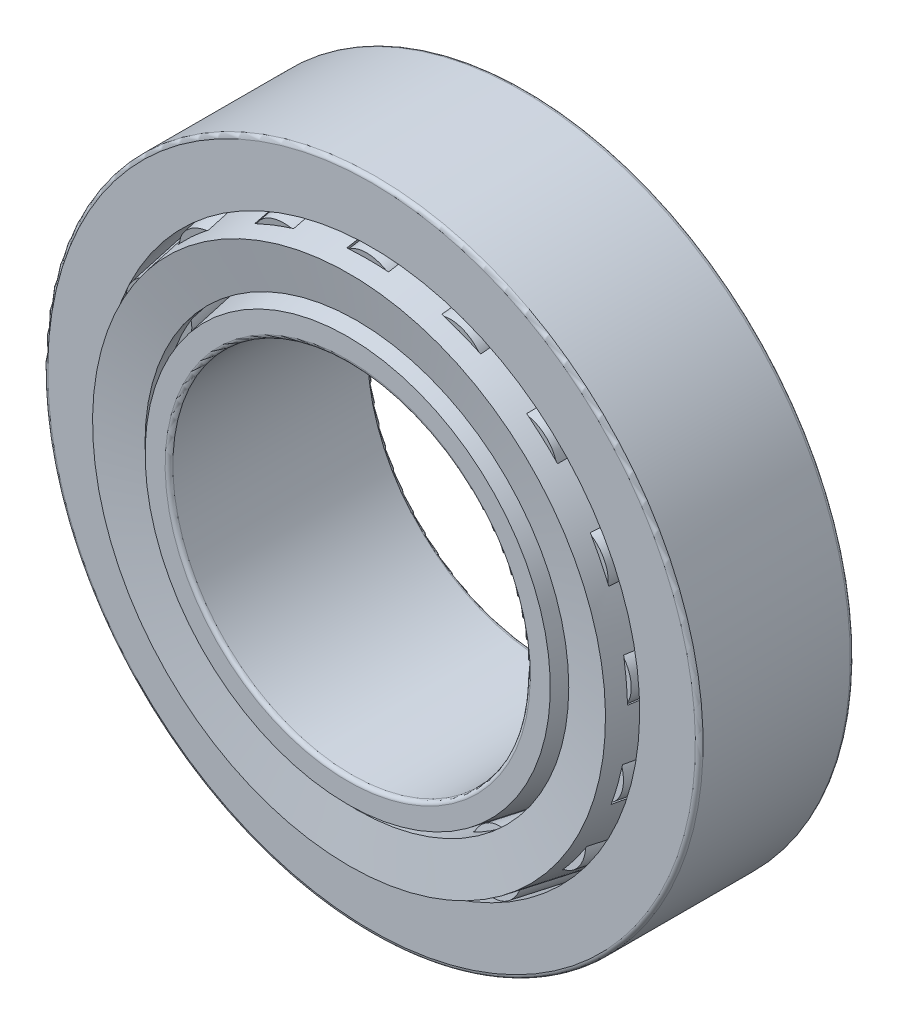
from build123d import *

# Parameters (mm, degrees)
CIRPATTERN2_COUNT = 17
CIRPATTERN1_COUNT = 17
FILLET1_R         = 0.325
FILLET2_R         = 0.325


with BuildPart() as part:
    # Sketch1 → Revolve1 (revolve)
    with BuildSketch(Plane(origin=(0, 0, 0), x_dir=(0, 0, -1), z_dir=(1, 0, 0))):
        Polygon((-6.5, 27.5), (6.5, 27.5), (6.5, 24.792250749), (-6.5, 22.5), align=None)
    revolve(axis=Axis((0, 0, 8.5), (0, 0, -1)))

    # Fillet1
    fillet1_edges = [part.edges().sort_by_distance(p)[0] for p in [
        (0, -27.5, -6.5),
        (0, -27.5, 6.5),
    ]]
    fillet(fillet1_edges, radius=FILLET1_R)


with BuildPart() as body_2:
    # Sketch5 → Revolve4 (revolve)
    with BuildSketch(Plane(origin=(0, 0, 0), x_dir=(0, 0, -1), z_dir=(1, 0, 0))):
        Polygon((8.5, 20), (-8.5, 17.002441328), (-8.5, 15), (8.5, 15), align=None)
    revolve(axis=Axis((0, 0, 8.5), (0, 0, -1)))

    # Fillet2
    fillet2_edges = [body_2.edges().sort_by_distance(p)[0] for p in [
        (0, -15, -8.5),
        (0, -15, 8.5),
    ]]
    fillet(fillet2_edges, radius=FILLET2_R)


with BuildPart() as body_3:
    # Sketch2 → Revolve2 (revolve)
    with BuildSketch(Plane(origin=(0, 0, 0), x_dir=(0, 0, -1), z_dir=(1, 0, 0))):
        Polygon((-8.390021185, 21.523625182), (-7.730148292, 17.781300044), (6.5, 20.290459127), (8.790021185, 20.694251649), (8.130148292, 24.436576787), (6.5, 24.14913766), align=None)
    revolve(axis=Axis((0, 0, 8.5), (0, 0, -1)))

    # Sketch3 → Cut-Revolve1 (revolve, cut)
    with BuildSketch(Plane(origin=(0, 0, 0), x_dir=(0, 0, -1), z_dir=(1, 0, 0))):
        Polygon((-6.5, 19.927547645), (-6.939915262, 22.42243107), (6.060084738, 24.714681819), (6.5, 22.219798394), align=None)
    cut_revolve1 = revolve(axis=Axis((0, 19.652462613, 8.060084738), (0, 0.17364817766692733, -0.9848077530122086)), mode=Mode.SUBTRACT)

    # CirPattern1: Cut-Revolve1 ×17 about axis
    cirpattern1_axis = Axis((0, 0, -8.5), (0, 0, 1))
    for i in range(1, CIRPATTERN1_COUNT):
        add(cut_revolve1.rotate(cirpattern1_axis, i * 360 / CIRPATTERN1_COUNT), mode=Mode.SUBTRACT)


with BuildPart() as body_4:
    # Sketch4 → Revolve3 (revolve)
    with BuildSketch(Plane(origin=(0, 0, 0), x_dir=(0, 0, -1), z_dir=(1, 0, 0))):
        Polygon((-6.917861943, 22.297360486), (6.082138057, 24.589611235), (6.5, 22.219798394), (-6.5, 19.927547645), align=None)
    revolve(axis=Axis((0, 19.652462613, 8.060084738), (0, 0.17364817766692733, -0.9848077530122086)))


with BuildPart() as cirpattern2_1:
    # CirPattern2: pattern copy
    add(body_4.part.rotate(Axis((0, 0, -8.5), (0, 0, 1)), 1 * 360 / CIRPATTERN2_COUNT))


with BuildPart() as cirpattern2_2:
    # CirPattern2: pattern copy
    add(body_4.part.rotate(Axis((0, 0, -8.5), (0, 0, 1)), 2 * 360 / CIRPATTERN2_COUNT))


with BuildPart() as cirpattern2_3:
    # CirPattern2: pattern copy
    add(body_4.part.rotate(Axis((0, 0, -8.5), (0, 0, 1)), 3 * 360 / CIRPATTERN2_COUNT))


with BuildPart() as cirpattern2_4:
    # CirPattern2: pattern copy
    add(body_4.part.rotate(Axis((0, 0, -8.5), (0, 0, 1)), 4 * 360 / CIRPATTERN2_COUNT))


with BuildPart() as cirpattern2_5:
    # CirPattern2: pattern copy
    add(body_4.part.rotate(Axis((0, 0, -8.5), (0, 0, 1)), 5 * 360 / CIRPATTERN2_COUNT))


with BuildPart() as cirpattern2_6:
    # CirPattern2: pattern copy
    add(body_4.part.rotate(Axis((0, 0, -8.5), (0, 0, 1)), 6 * 360 / CIRPATTERN2_COUNT))


with BuildPart() as cirpattern2_7:
    # CirPattern2: pattern copy
    add(body_4.part.rotate(Axis((0, 0, -8.5), (0, 0, 1)), 7 * 360 / CIRPATTERN2_COUNT))


with BuildPart() as cirpattern2_8:
    # CirPattern2: pattern copy
    add(body_4.part.rotate(Axis((0, 0, -8.5), (0, 0, 1)), 8 * 360 / CIRPATTERN2_COUNT))


with BuildPart() as cirpattern2_9:
    # CirPattern2: pattern copy
    add(body_4.part.rotate(Axis((0, 0, -8.5), (0, 0, 1)), 9 * 360 / CIRPATTERN2_COUNT))


with BuildPart() as cirpattern2_10:
    # CirPattern2: pattern copy
    add(body_4.part.rotate(Axis((0, 0, -8.5), (0, 0, 1)), 10 * 360 / CIRPATTERN2_COUNT))


with BuildPart() as cirpattern2_11:
    # CirPattern2: pattern copy
    add(body_4.part.rotate(Axis((0, 0, -8.5), (0, 0, 1)), 11 * 360 / CIRPATTERN2_COUNT))


with BuildPart() as cirpattern2_12:
    # CirPattern2: pattern copy
    add(body_4.part.rotate(Axis((0, 0, -8.5), (0, 0, 1)), 12 * 360 / CIRPATTERN2_COUNT))


with BuildPart() as cirpattern2_13:
    # CirPattern2: pattern copy
    add(body_4.part.rotate(Axis((0, 0, -8.5), (0, 0, 1)), 13 * 360 / CIRPATTERN2_COUNT))


with BuildPart() as cirpattern2_14:
    # CirPattern2: pattern copy
    add(body_4.part.rotate(Axis((0, 0, -8.5), (0, 0, 1)), 14 * 360 / CIRPATTERN2_COUNT))


with BuildPart() as cirpattern2_15:
    # CirPattern2: pattern copy
    add(body_4.part.rotate(Axis((0, 0, -8.5), (0, 0, 1)), 15 * 360 / CIRPATTERN2_COUNT))


with BuildPart() as cirpattern2_16:
    # CirPattern2: pattern copy
    add(body_4.part.rotate(Axis((0, 0, -8.5), (0, 0, 1)), 16 * 360 / CIRPATTERN2_COUNT))


solid = Compound([part.part, body_2.part, body_3.part, body_4.part, cirpattern2_1.part, cirpattern2_2.part, cirpattern2_3.part, cirpattern2_4.part, cirpattern2_5.part, cirpattern2_6.part, cirpattern2_7.part, cirpattern2_8.part, cirpattern2_9.part, cirpattern2_10.part, cirpattern2_11.part, cirpattern2_12.part, cirpattern2_13.part, cirpattern2_14.part, cirpattern2_15.part, cirpattern2_16.part])
